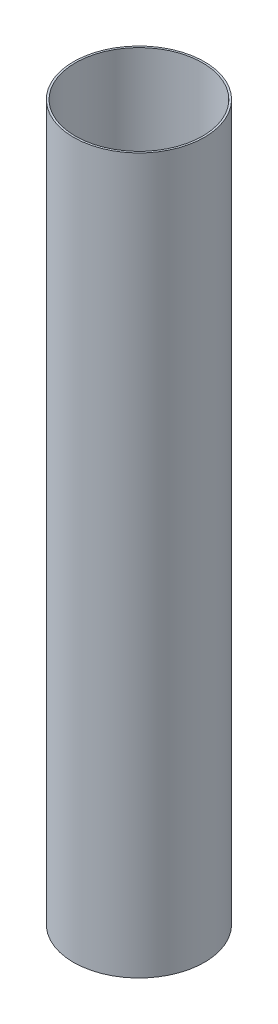
from build123d import *

# Parameters (mm, degrees)
CROQUIS1_R              = 55
CROQUIS1_R_2            = 53.4
SALIENTE_EXTRUIR1_DEPTH = 600


with BuildPart() as part:
    # Croquis1 → Saliente-Extruir1 (new body)
    with BuildSketch(Plane(origin=(0, 0, 0), x_dir=(1, 0, 0), z_dir=(0, 1, 0))):
        Circle(CROQUIS1_R)
        Circle(CROQUIS1_R_2, mode=Mode.SUBTRACT)
    extrude(amount=SALIENTE_EXTRUIR1_DEPTH)


solid = part.part
